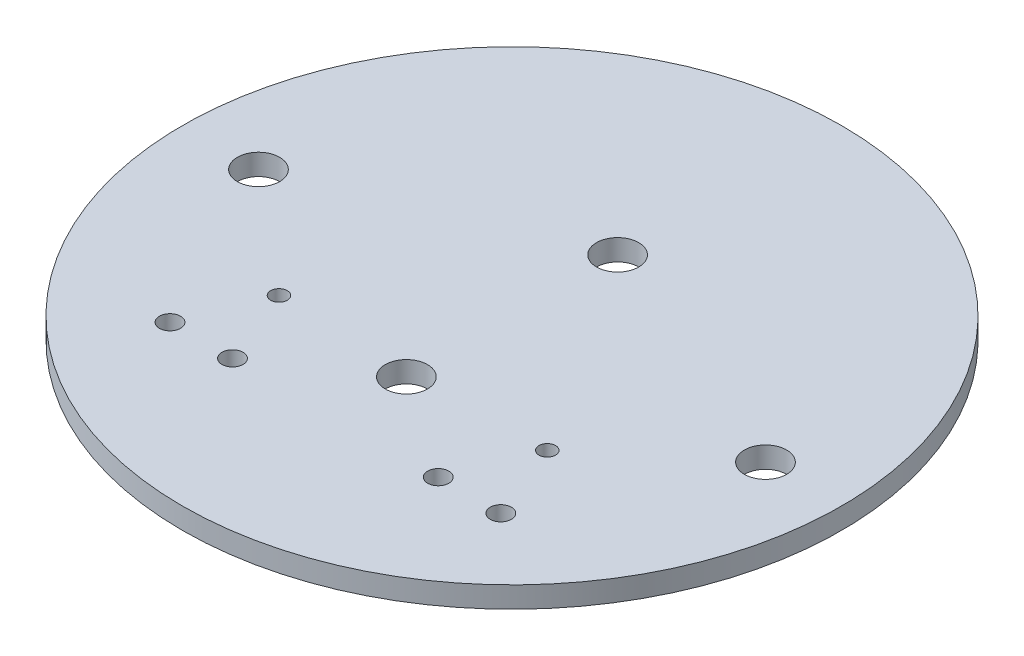
from build123d import *

# Parameters (mm, degrees)
SKETCH1_R           = 49.53
BOSS_EXTRUDE1_DEPTH = 3.175
SKETCH2_R           = 3.175
CUT_EXTRUDE1_DEPTH  = 263.398
SKETCH3_R           = 3.175
CUT_EXTRUDE2_DEPTH  = 25.4
SKETCH4_R           = 1.5875
SKETCH4_R_2         = 1.25
CUT_EXTRUDE3_DEPTH  = 50.8


with BuildPart() as part:
    # Sketch1 → Boss-Extrude1 (new body)
    with BuildSketch(Plane(origin=(0, 0, 0), x_dir=(1, 0, 0), z_dir=(0, 1, 0))):
        Circle(SKETCH1_R)
    extrude(amount=BOSS_EXTRUDE1_DEPTH)

    # Sketch2 → Cut-Extrude1 (cut)
    with BuildSketch(Plane(origin=(-55.039702575, 234.95, -116.088398355), x_dir=(-1, 0, 0), z_dir=(0, 1, 0))):
        with Locations((-93.139702575, 116.088398355)):
            Circle(SKETCH2_R)
        with Locations((-16.939702575, 116.088398355)):
            Circle(SKETCH2_R)
    extrude(amount=-CUT_EXTRUDE1_DEPTH, mode=Mode.SUBTRACT)

    # Sketch3 → Cut-Extrude2 (cut)
    with BuildSketch(Plane(origin=(-28.264398128, 0, -82.371298873), x_dir=(1, 0, 0), z_dir=(0, -1, 0))):
        with Locations((28.264398128, 98.246298873)):
            Circle(SKETCH3_R)
        with Locations((28.264398128, 66.496298873)):
            Circle(SKETCH3_R)
    extrude(amount=-CUT_EXTRUDE2_DEPTH, mode=Mode.SUBTRACT)

    # Sketch4 → Cut-Extrude3 (cut)
    with BuildSketch(Plane(origin=(-28.264398128, 0, -82.371298873), x_dir=(-1, 0, 0), z_dir=(0, -1, 0))):
        with Locations((-3.404148128, -108.914298873)):
            Circle(SKETCH4_R)
        with Locations((-12.802148128, -108.914298873)):
            Circle(SKETCH4_R)
        with Locations((-43.726648128, -108.914298873)):
            Circle(SKETCH4_R)
        with Locations((-53.124648128, -108.914298873)):
            Circle(SKETCH4_R)
        with Locations((-8.103148128, -97.230298873)):
            Circle(SKETCH4_R_2)
        with Locations((-48.425648128, -97.230298873)):
            Circle(SKETCH4_R_2)
    extrude(amount=-CUT_EXTRUDE3_DEPTH, mode=Mode.SUBTRACT)


solid = part.part
